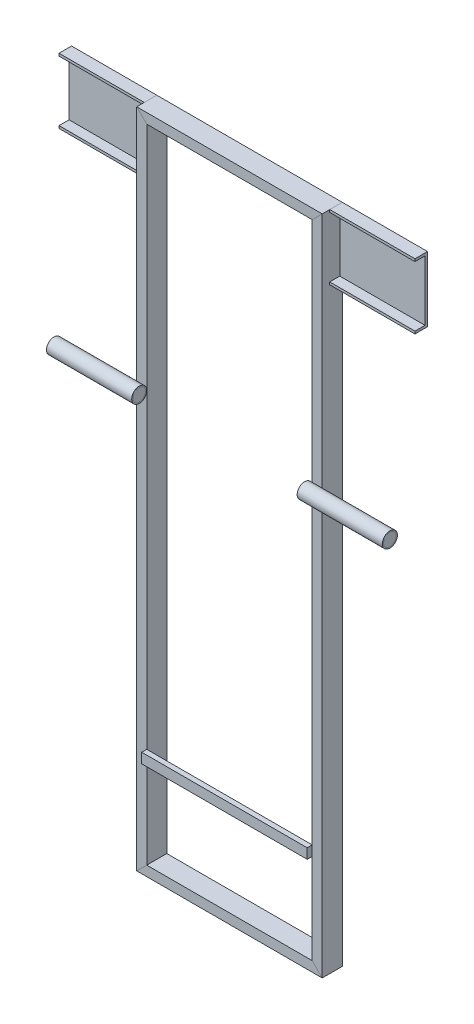
from build123d import *

# Parameters (mm, degrees)
RECTANGULAR_TUBE_50_X_30_X_2_6_1_DEPTH   = 1300
RECTANGULAR_TUBE_50_X_30_X_2_6_1_2_DEPTH = 1300
RECTANGULAR_TUBE_50_X_30_X_2_6_4_DEPTH   = 350
RECTANGULAR_TUBE_50_X_30_X_2_6_4_2_DEPTH = 350
BODY_2_RUN_ON_DEPTH                      = 10
BODY_START                               = 350
BODY_4_RUN_ON_DEPTH                      = 10
PART_RUN_ON_DEPTH                        = 10
BODY_4_RUN_ON_2_DEPTH                    = 10
PART_START                               = 1300
PART_RUN_ON_2_DEPTH                      = 10
BODY_3_RUN_ON_DEPTH                      = 10
BODY_START_2                             = 1300
BODY_2_RUN_ON_2_DEPTH                    = 10
BODY_3_RUN_ON_2_DEPTH                    = 10
SKETCH14_W                               = 330
SKETCH14_H                               = 20
BOSS_EXTRUDE1_DEPTH                      = 10
C_CHANNEL_120_X_12_5_DEPTH               = 170
C_CHANNEL_120_X_12_5_2_DEPTH             = 170
SKETCH114_R                              = 15
SKETCH114_R_2                            = 12.5
PIPE_21_3_X_2_3_1_DEPTH                  = 170
SKETCH114_ON_SEGMENT_2_R                 = 15
SKETCH114_ON_SEGMENT_2_R_2               = 12.5
PIPE_21_3_X_2_3_1_2_DEPTH                = 170


with BuildPart() as part:
    # Sketch11 → Rectangular tube 50 X 30 X 2.6(1) (new body)
    with BuildSketch(Plane(origin=(0, 0, -20), x_dir=(-1, 0, 0), z_dir=(0, 1, 0))):
        Polygon((-4.8, -20), (4.8, -20), (10, -20), (10, -14.8), (10, 14.8), (10, 20), (4.8, 20), (-4.8, 20), (-10, 20), (-10, 14.8), (-10, -14.8), (-10, -20), align=None)
        Polygon((-4.8, -17.4), (4.8, -17.4), (7.4, -17.4), (7.4, -14.8), (7.4, 14.8), (7.4, 17.4), (4.8, 17.4), (-4.8, 17.4), (-7.4, 17.4), (-7.4, 14.8), (-7.4, -14.8), (-7.4, -17.4), align=None, mode=Mode.SUBTRACT)
    extrude(amount=RECTANGULAR_TUBE_50_X_30_X_2_6_1_DEPTH)

    # Sketch11 → part run on (add)
    with BuildSketch(Plane(origin=(0, 0, -20), x_dir=(-1, 0, 0), z_dir=(0, 1, 0))):
        Polygon((-4.8, -20), (4.8, -20), (10, -20), (10, -14.8), (10, 14.8), (10, 20), (4.8, 20), (-4.8, 20), (-10, 20), (-10, 14.8), (-10, -14.8), (-10, -20), align=None)
        Polygon((-4.8, -17.4), (4.8, -17.4), (7.4, -17.4), (7.4, -14.8), (7.4, 14.8), (7.4, 17.4), (4.8, 17.4), (-4.8, 17.4), (-7.4, 17.4), (-7.4, 14.8), (-7.4, -14.8), (-7.4, -17.4), align=None, mode=Mode.SUBTRACT)
    extrude(amount=-PART_RUN_ON_DEPTH)

    # Trim/Extend2
    split(bisect_by=Plane(origin=(0, 0, 0), x_dir=(-0.707106781, -0.707106781, 0), z_dir=(-0.707106781, 0.707106781, 0)), keep=Keep.TOP)

    # Sketch11 → part run on 2 (add)
    with BuildSketch(Plane(origin=(0, 0, -20), x_dir=(-1, 0, 0), z_dir=(0, 1, 0)).offset(PART_START)):
        Polygon((-4.8, -20), (4.8, -20), (10, -20), (10, -14.8), (10, 14.8), (10, 20), (4.8, 20), (-4.8, 20), (-10, 20), (-10, 14.8), (-10, -14.8), (-10, -20), align=None)
        Polygon((-4.8, -17.4), (4.8, -17.4), (7.4, -17.4), (7.4, -14.8), (7.4, 14.8), (7.4, 17.4), (4.8, 17.4), (-4.8, 17.4), (-7.4, 17.4), (-7.4, 14.8), (-7.4, -14.8), (-7.4, -17.4), align=None, mode=Mode.SUBTRACT)
    extrude(amount=PART_RUN_ON_2_DEPTH)

    # Trim/Extend4
    split(bisect_by=Plane(origin=(0, 1300, 0), x_dir=(0.707106781, -0.707106781, 0), z_dir=(-0.707106781, -0.707106781, 0)), keep=Keep.TOP)


with BuildPart() as body_2:
    # Sketch11 on segment 2 (carried to segment 2) → Rectangular tube 50 X 30 X 2.6_1 2 (new body)
    with BuildSketch(Plane(origin=(350, 0, -20), x_dir=(-1, 0, 0), z_dir=(0, 1, 0))):
        Polygon((-4.8, -20), (4.8, -20), (10, -20), (10, -14.8), (10, 14.8), (10, 20), (4.8, 20), (-4.8, 20), (-10, 20), (-10, 14.8), (-10, -14.8), (-10, -20), align=None)
        Polygon((-4.8, -17.4), (4.8, -17.4), (7.4, -17.4), (7.4, -14.8), (7.4, 14.8), (7.4, 17.4), (4.8, 17.4), (-4.8, 17.4), (-7.4, 17.4), (-7.4, 14.8), (-7.4, -14.8), (-7.4, -17.4), align=None, mode=Mode.SUBTRACT)
    extrude(amount=RECTANGULAR_TUBE_50_X_30_X_2_6_1_2_DEPTH)

    # Sketch11 on segment 2 (carried to segment 2) → body 2 run on (add)
    with BuildSketch(Plane(origin=(350, 0, -20), x_dir=(-1, 0, 0), z_dir=(0, 1, 0))):
        Polygon((-4.8, -20), (4.8, -20), (10, -20), (10, -14.8), (10, 14.8), (10, 20), (4.8, 20), (-4.8, 20), (-10, 20), (-10, 14.8), (-10, -14.8), (-10, -20), align=None)
        Polygon((-4.8, -17.4), (4.8, -17.4), (7.4, -17.4), (7.4, -14.8), (7.4, 14.8), (7.4, 17.4), (4.8, 17.4), (-4.8, 17.4), (-7.4, 17.4), (-7.4, 14.8), (-7.4, -14.8), (-7.4, -17.4), align=None, mode=Mode.SUBTRACT)
    extrude(amount=-BODY_2_RUN_ON_DEPTH)

    # Trim/Extend1
    split(bisect_by=Plane(origin=(350, 0, 0), x_dir=(-0.707106781, 0.707106781, 0), z_dir=(0.707106781, 0.707106781, 0)), keep=Keep.TOP)

    # Sketch11 on segment 2 (carried to segment 2) → body 2 run on 2 (add)
    with BuildSketch(Plane(origin=(350, 0, -20), x_dir=(-1, 0, 0), z_dir=(0, 1, 0)).offset(BODY_START_2)):
        Polygon((-4.8, -20), (4.8, -20), (10, -20), (10, -14.8), (10, 14.8), (10, 20), (4.8, 20), (-4.8, 20), (-10, 20), (-10, 14.8), (-10, -14.8), (-10, -20), align=None)
        Polygon((-4.8, -17.4), (4.8, -17.4), (7.4, -17.4), (7.4, -14.8), (7.4, 14.8), (7.4, 17.4), (4.8, 17.4), (-4.8, 17.4), (-7.4, 17.4), (-7.4, 14.8), (-7.4, -14.8), (-7.4, -17.4), align=None, mode=Mode.SUBTRACT)
    extrude(amount=BODY_2_RUN_ON_2_DEPTH)

    # Trim/Extend5
    split(bisect_by=Plane(origin=(350, 1300, 0), x_dir=(0.707106781, 0.707106781, 0), z_dir=(0.707106781, -0.707106781, 0)), keep=Keep.TOP)


with BuildPart() as body_3:
    # Sketch12 → Rectangular tube 50 X 30 X 2.6(4) (new body)
    with BuildSketch(Plane(origin=(0, 1300, -20), x_dir=(0, 1, 0), z_dir=(1, 0, 0))):
        Polygon((-4.8, -20), (4.8, -20), (10, -20), (10, -14.8), (10, 14.8), (10, 20), (4.8, 20), (-4.8, 20), (-10, 20), (-10, 14.8), (-10, -14.8), (-10, -20), align=None)
        Polygon((-4.8, -17.4), (4.8, -17.4), (7.4, -17.4), (7.4, -14.8), (7.4, 14.8), (7.4, 17.4), (4.8, 17.4), (-4.8, 17.4), (-6.687524796, 17.4), (-7.4, 17.4), (-7.4, 14.8), (-7.4, -14.8), (-7.4, -17.4), align=None, mode=Mode.SUBTRACT)
    extrude(amount=RECTANGULAR_TUBE_50_X_30_X_2_6_4_DEPTH)

    # Sketch12 → body 3 run on (add)
    with BuildSketch(Plane(origin=(0, 1300, -20), x_dir=(0, 1, 0), z_dir=(1, 0, 0))):
        Polygon((-4.8, -20), (4.8, -20), (10, -20), (10, -14.8), (10, 14.8), (10, 20), (4.8, 20), (-4.8, 20), (-10, 20), (-10, 14.8), (-10, -14.8), (-10, -20), align=None)
        Polygon((-4.8, -17.4), (4.8, -17.4), (7.4, -17.4), (7.4, -14.8), (7.4, 14.8), (7.4, 17.4), (4.8, 17.4), (-4.8, 17.4), (-6.687524796, 17.4), (-7.4, 17.4), (-7.4, 14.8), (-7.4, -14.8), (-7.4, -17.4), align=None, mode=Mode.SUBTRACT)
    extrude(amount=-BODY_3_RUN_ON_DEPTH)

    # Trim/Extend4
    split(bisect_by=Plane(origin=(0, 1300, 0), x_dir=(-0.707106781, 0.707106781, 0), z_dir=(0.707106781, 0.707106781, 0)), keep=Keep.TOP)

    # Sketch12 → body 3 run on 2 (add)
    with BuildSketch(Plane(origin=(0, 1300, -20), x_dir=(0, 1, 0), z_dir=(1, 0, 0)).offset(BODY_START)):
        Polygon((-4.8, -20), (4.8, -20), (10, -20), (10, -14.8), (10, 14.8), (10, 20), (4.8, 20), (-4.8, 20), (-10, 20), (-10, 14.8), (-10, -14.8), (-10, -20), align=None)
        Polygon((-4.8, -17.4), (4.8, -17.4), (7.4, -17.4), (7.4, -14.8), (7.4, 14.8), (7.4, 17.4), (4.8, 17.4), (-4.8, 17.4), (-6.687524796, 17.4), (-7.4, 17.4), (-7.4, 14.8), (-7.4, -14.8), (-7.4, -17.4), align=None, mode=Mode.SUBTRACT)
    extrude(amount=BODY_3_RUN_ON_2_DEPTH)

    # Trim/Extend5
    split(bisect_by=Plane(origin=(350, 1300, 0), x_dir=(-0.707106781, -0.707106781, 0), z_dir=(-0.707106781, 0.707106781, 0)), keep=Keep.TOP)


with BuildPart() as body_4:
    # Sketch12 on segment 2 (carried to segment 2) → Rectangular tube 50 X 30 X 2.6_4 2 (new body)
    with BuildSketch(Plane(origin=(0, 0, -20), x_dir=(0, 1, 0), z_dir=(1, 0, 0))):
        Polygon((-4.8, -20), (4.8, -20), (10, -20), (10, -14.8), (10, 14.8), (10, 20), (4.8, 20), (-4.8, 20), (-10, 20), (-10, 14.8), (-10, -14.8), (-10, -20), align=None)
        Polygon((-4.8, -17.4), (4.8, -17.4), (7.4, -17.4), (7.4, -14.8), (7.4, 14.8), (7.4, 17.4), (4.8, 17.4), (-4.8, 17.4), (-6.687524796, 17.4), (-7.4, 17.4), (-7.4, 14.8), (-7.4, -14.8), (-7.4, -17.4), align=None, mode=Mode.SUBTRACT)
    extrude(amount=RECTANGULAR_TUBE_50_X_30_X_2_6_4_2_DEPTH)

    # Sketch12 on segment 2 (carried to segment 2) → body 4 run on (add)
    with BuildSketch(Plane(origin=(0, 0, -20), x_dir=(0, 1, 0), z_dir=(1, 0, 0)).offset(BODY_START)):
        Polygon((-4.8, -20), (4.8, -20), (10, -20), (10, -14.8), (10, 14.8), (10, 20), (4.8, 20), (-4.8, 20), (-10, 20), (-10, 14.8), (-10, -14.8), (-10, -20), align=None)
        Polygon((-4.8, -17.4), (4.8, -17.4), (7.4, -17.4), (7.4, -14.8), (7.4, 14.8), (7.4, 17.4), (4.8, 17.4), (-4.8, 17.4), (-6.687524796, 17.4), (-7.4, 17.4), (-7.4, 14.8), (-7.4, -14.8), (-7.4, -17.4), align=None, mode=Mode.SUBTRACT)
    extrude(amount=BODY_4_RUN_ON_DEPTH)

    # Trim/Extend1
    split(bisect_by=Plane(origin=(350, 0, 0), x_dir=(0.707106781, -0.707106781, 0), z_dir=(-0.707106781, -0.707106781, 0)), keep=Keep.TOP)

    # Sketch12 on segment 2 (carried to segment 2) → body 4 run on 2 (add)
    with BuildSketch(Plane(origin=(0, 0, -20), x_dir=(0, 1, 0), z_dir=(1, 0, 0))):
        Polygon((-4.8, -20), (4.8, -20), (10, -20), (10, -14.8), (10, 14.8), (10, 20), (4.8, 20), (-4.8, 20), (-10, 20), (-10, 14.8), (-10, -14.8), (-10, -20), align=None)
        Polygon((-4.8, -17.4), (4.8, -17.4), (7.4, -17.4), (7.4, -14.8), (7.4, 14.8), (7.4, 17.4), (4.8, 17.4), (-4.8, 17.4), (-6.687524796, 17.4), (-7.4, 17.4), (-7.4, 14.8), (-7.4, -14.8), (-7.4, -17.4), align=None, mode=Mode.SUBTRACT)
    extrude(amount=-BODY_4_RUN_ON_2_DEPTH)

    # Trim/Extend2
    split(bisect_by=Plane(origin=(0, 0, 0), x_dir=(0.707106781, 0.707106781, 0), z_dir=(0.707106781, -0.707106781, 0)), keep=Keep.TOP)


with BuildPart() as body_5:
    # Sketch14 → Boss-Extrude1 (new body)
    with BuildSketch(Plane.XY):
        with Locations((175, 200)):
            Rectangle(SKETCH14_W, SKETCH14_H)
    extrude(amount=BOSS_EXTRUDE1_DEPTH)


with BuildPart() as body_6:
    # Sketch111 → C channel 120 X 12(5) (new body)
    with BuildSketch(Plane(origin=(-10, 1180, -40), x_dir=(0, 0, 1), z_dir=(-1, 0, 0))):
        Polygon((25, 130), (0, 130), (0, 0), (25, 0), (25, 5), (5, 5), (5, 18.27), (5, 101.74), (5, 125), (13.463772294, 125), (25, 125), align=None)
    extrude(amount=C_CHANNEL_120_X_12_5_DEPTH)


with BuildPart() as body_7:
    # Sketch111 on segment 2 (carried to segment 2) → C channel 120 X 12_5 2 (new body)
    with BuildSketch(Plane(origin=(530, 1180, -40), x_dir=(0, 0, 1), z_dir=(-1, 0, 0))):
        Polygon((25, 130), (0, 130), (0, 0), (25, 0), (25, 5), (5, 5), (5, 18.27), (5, 101.74), (5, 125), (13.463772294, 125), (25, 125), align=None)
    extrude(amount=C_CHANNEL_120_X_12_5_2_DEPTH)


with BuildPart() as body_8:
    # Sketch114 → Pipe 21.3 X 2.3(1) (new body)
    with BuildSketch(Plane(origin=(340, 830, 15), x_dir=(0, 1, 0), z_dir=(1, 0, 0))):
        Circle(SKETCH114_R)
        Circle(SKETCH114_R_2, mode=Mode.SUBTRACT)
    extrude(amount=PIPE_21_3_X_2_3_1_DEPTH)


with BuildPart() as body_9:
    # Sketch114 on segment 2 (carried to segment 2) → Pipe 21.3 X 2.3_1 2 (new body)
    with BuildSketch(Plane(origin=(-160, 830, 15), x_dir=(0, 1, 0), z_dir=(1, 0, 0))):
        Circle(SKETCH114_ON_SEGMENT_2_R)
        Circle(SKETCH114_ON_SEGMENT_2_R_2, mode=Mode.SUBTRACT)
    extrude(amount=PIPE_21_3_X_2_3_1_2_DEPTH)


solid = Compound([part.part, body_2.part, body_3.part, body_4.part, body_5.part, body_6.part, body_7.part, body_8.part, body_9.part])
